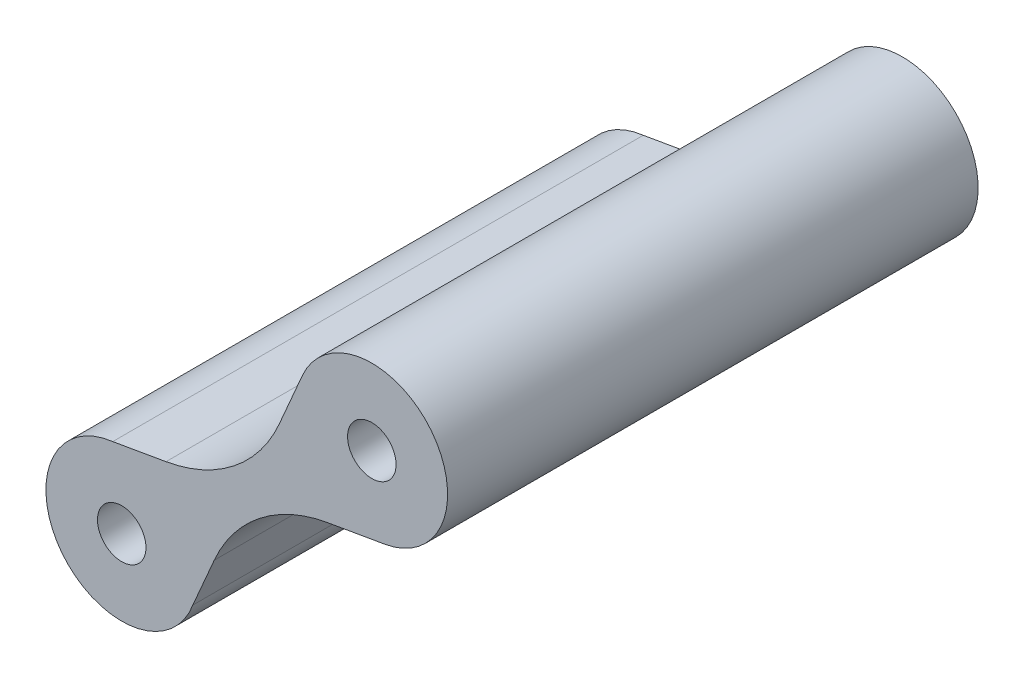
from build123d import *

# Parameters (mm, degrees)
SKETCH1_R           = 1.6
BOSS_EXTRUDE1_DEPTH = 35


with BuildPart() as part:
    # Sketch1 → Boss-Extrude1 (new body)
    with BuildSketch(Plane(origin=(0, 0, 0), x_dir=(-1, 0, 0), z_dir=(0, 0, 1))):
        with BuildLine():
            ThreePointArc((6.106952435, -11.464428538), (9.097104038, -7.574548586), (13.577547372, -5.575098618))
            Line((13.577547372, -5.575098618), (17.094474376, -4.96453424))
            ThreePointArc((17.094474376, -4.96453424), (20.427458361, 3.094361133), (11.812394993, 1.739643439))
            Line((11.812394993, 1.739643439), (10.395840134, -1.536777892))
            ThreePointArc((10.395840134, -1.536777892), (7.403500619, -5.424975016), (2.921933136, -7.421904043))
            Line((2.921933136, -7.421904043), (-0.867040687, -8.0775021))
            ThreePointArc((-0.867040687, -8.0775021), (-3.926102771, -16.093293092), (4.58295671, -14.994806488))
            Line((4.58295671, -14.994806488), (6.106952435, -11.464428538))
        make_face()
        with Locations((0, -13)):
            Circle(SKETCH1_R, mode=Mode.SUBTRACT)
        with Locations((16.5, 0)):
            Circle(SKETCH1_R, mode=Mode.SUBTRACT)
    extrude(amount=BOSS_EXTRUDE1_DEPTH)


solid = part.part
